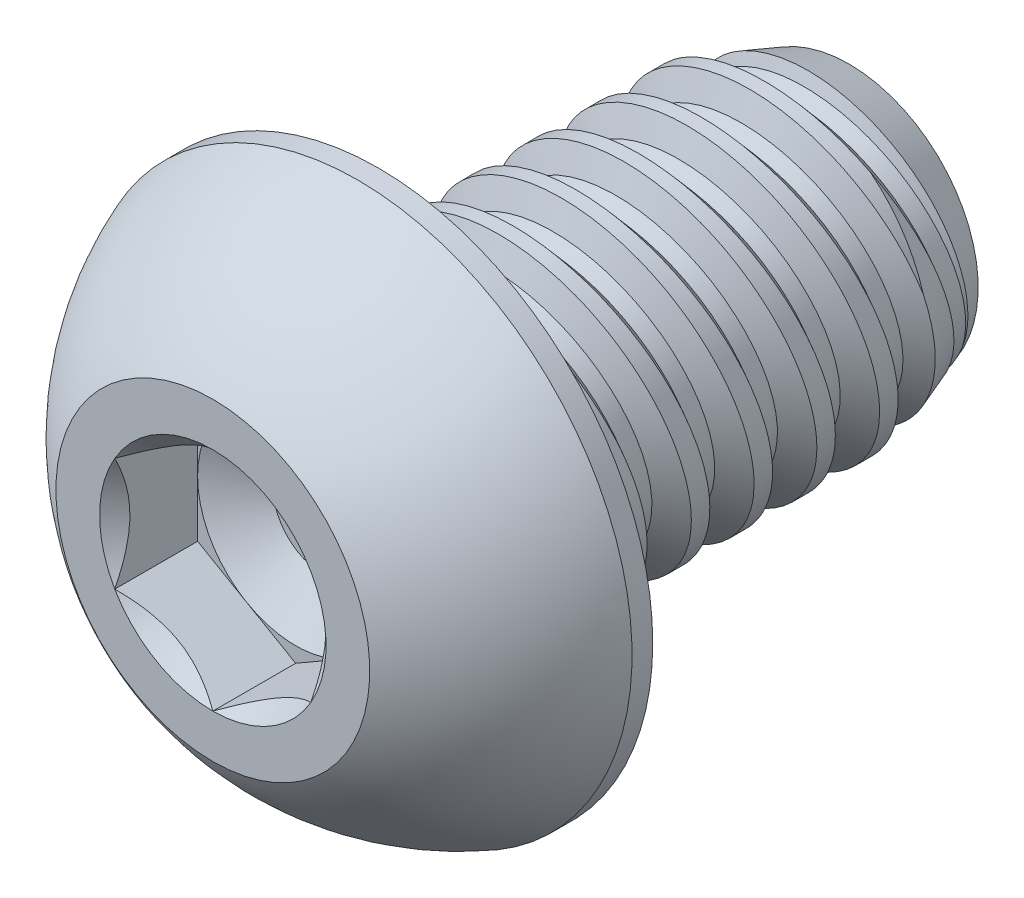
from build123d import *

# Parameters (mm, degrees)
SKETCH1_W          = 9.525
SKETCH1_H          = 3.175
LPATTERN1_COUNT    = 7
LPATTERN1_PITCH    = 1.27
LPATTERN2_COUNT    = 2
LPATTERN2_PITCH    = 1.27
SKETCH4_R          = 5.5499
EXTRUDE1_DEPTH     = 3.3528
CUT_EXTRUDE1_DEPTH = 1.6764
SKETCH7_R          = 2.291358881
CUT_EXTRUDE4_DEPTH = 1.6764
CUT_EXTRUDE4_TAPER = 45
SKETCH8_R          = 1.984375
CUT_EXTRUDE5_DEPTH = 0.5588
CUT_EXTRUDE5_TAPER = 60


with BuildPart() as part:
    # Sketch1 → Revolve1 (revolve)
    with BuildSketch(Plane(origin=(0, 0, 0), x_dir=(0, 0, -1), z_dir=(1, 0, 0))):
        with Locations((4.7625, 1.5875)):
            Rectangle(SKETCH1_W, SKETCH1_H)
    revolve(axis=Axis((0, 0, 0), (0, 0, 1)))

    # Sketch2 → Cut-Revolve1 (revolve, cut)
    with BuildSketch(Plane(origin=(0, 0, 0), x_dir=(0, 0, -1), z_dir=(1, 0, 0))):
        Polygon((0.155667182, 3.206133436), (1.245337458, 3.424067492), (0.990981237, 2.672175229), (0.679646872, 2.609908356), align=None)
    cut_revolve1 = revolve(axis=Axis((0, -0.272704483, 0), (0, 0.196116135, -0.980580676)), mode=Mode.SUBTRACT)

    # Sketch3 → Cut-Revolve2 (revolve, cut)
    with BuildSketch(Plane(origin=(0, 0, 0), x_dir=(0, 0, -1), z_dir=(1, 0, 0))):
        Polygon((9.525, 2.609908356), (7.972423467, 3.175), (9.525, 3.175), align=None)
    revolve(axis=Axis((0, 0, -7.972423467), (0, 0, 1)), mode=Mode.SUBTRACT)

    # LPattern1: Cut-Revolve1 ×7
    with Locations(*[(0, 0, -i * LPATTERN1_PITCH) for i in range(1, LPATTERN1_COUNT)]):
        add(cut_revolve1, mode=Mode.SUBTRACT)

    # LPattern2: Cut-Revolve1 ×2
    with Locations(*[(0, 0, i * LPATTERN2_PITCH) for i in range(1, LPATTERN2_COUNT)]):
        add(cut_revolve1, mode=Mode.SUBTRACT)

    # Sketch4 → Extrude1 (add)
    with BuildSketch(Plane.XY):
        Circle(SKETCH4_R)
    extrude(amount=EXTRUDE1_DEPTH)

    # Sketch9 → Cut-Revolve3 (revolve, cut)
    with BuildSketch(Plane(origin=(0, 0, 0), x_dir=(0, 0, -1), z_dir=(1, 0, 0))):
        with BuildLine():
            Line((0, 5.5499), (-0.4191, 5.5499))
            ThreePointArc((-0.4191, 5.5499), (-2.080242127, 4.602457922), (-3.3528, 3.175))
            Line((-3.3528, 3.175), (-3.7719, 3.175))
            Line((-3.7719, 3.175), (-3.7719, 5.969))
            Line((-3.7719, 5.969), (0, 5.969))
            Line((0, 5.969), (0, 5.5499))
        make_face()
    revolve(axis=Axis((0, 0, 0), (0, 0, 1)), mode=Mode.SUBTRACT)

    # Sketch6 → Cut-Extrude1 (cut)
    with BuildSketch(Plane.XY.offset(3.3528)):
        Polygon((0, -2.291358881), (1.984375, -1.14567944), (1.984375, 1.14567944), (0, 2.291358881), (-1.984375, 1.14567944), (-1.984375, -1.14567944), align=None)
    extrude(amount=-CUT_EXTRUDE1_DEPTH, mode=Mode.SUBTRACT)

    # Sketch7 → Cut-Extrude4 (cut)
    with BuildSketch(Plane.XY.offset(3.3528)):
        Circle(SKETCH7_R)
    extrude(amount=-CUT_EXTRUDE4_DEPTH, taper=CUT_EXTRUDE4_TAPER, mode=Mode.SUBTRACT)

    # Sketch8 → Cut-Extrude5 (cut)
    with BuildSketch(Plane.XY.offset(1.6764)):
        Circle(SKETCH8_R)
    extrude(amount=-CUT_EXTRUDE5_DEPTH, taper=CUT_EXTRUDE5_TAPER, mode=Mode.SUBTRACT)


solid = part.part
